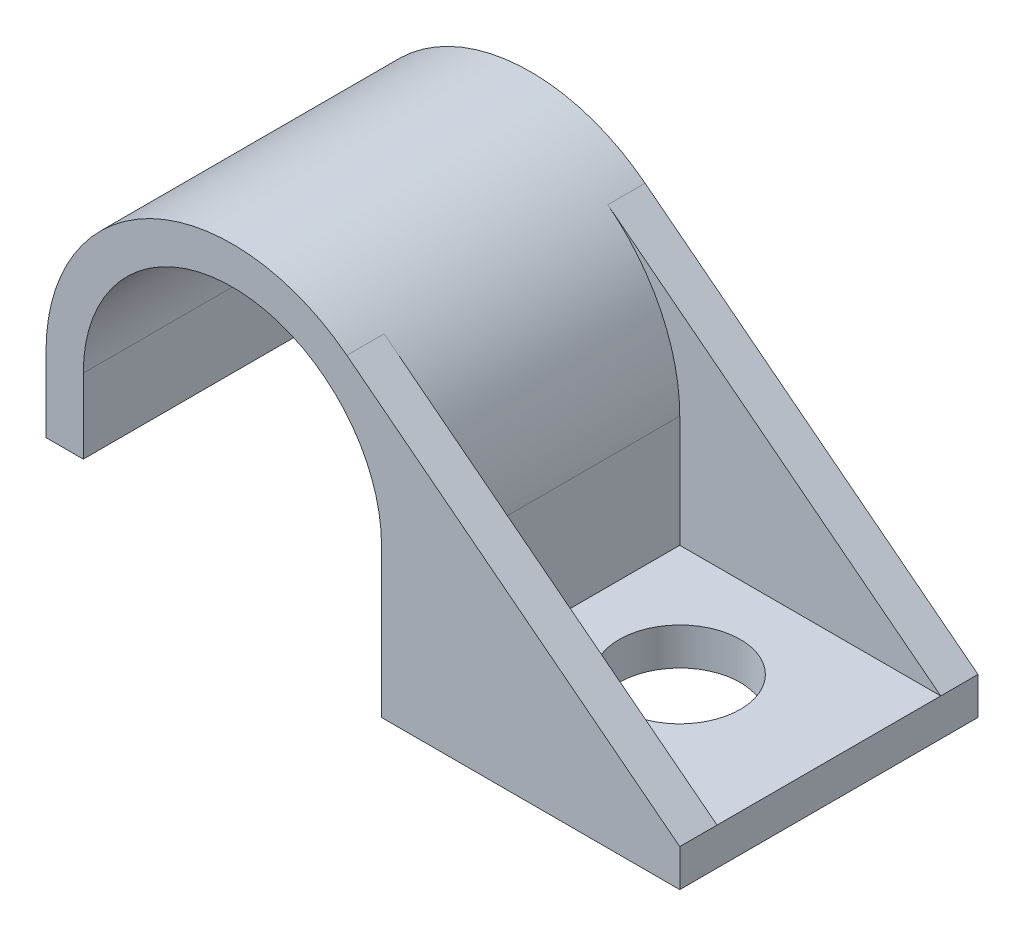
from build123d import *

# Parameters (mm, degrees)
BOSS_EXTRUDE1_DEPTH            = 6.35
CUT_EXTRUDE3_START             = 1.5875
SKETCH4_W                      = 11.112499999999997
SKETCH4_H                      = 9.524999999999999
CUT_EXTRUDE3_DEPTH             = 24.057127330312788
CUT_EXTRUDE4_REACH             = 26.645
CUT_EXTRUDE4_DIRECTION_2_REACH = 26.645
SKETCH3_R                      = 2.5796875
CUT_EXTRUDE2_DEPTH             = 2.54


with BuildPart() as part:
    # Sketch1 → Boss-Extrude1 (new, symmetric)
    with BuildSketch(Plane.XY):
        with BuildLine():
            Line((-7.9375, 3.174999999999999), (-7.9375, 6.35))
            ThreePointArc((-7.9375, 6.35), (-3.487109685994719, 13.480495935616386), (4.873579631582188, 12.615151859662083))
            Line((4.873579631582188, 12.615151859662083), (19.049999999999997, 1.5875000000000004))
            Line((19.049999999999997, 1.5875000000000004), (19.049999999999997, 0))
            Line((19.049999999999997, 0), (6.350000000000001, -1.56e-15))
            Line((6.350000000000001, -1.56e-15), (6.35, 6.3500000000000005))
            ThreePointArc((6.35, 6.3500000000000005), (-1.02e-15, 12.7), (-6.35, 6.349999999999999))
            Line((-6.35, 6.349999999999999), (-6.35, 3.175))
            Line((-6.35, 3.175), (-7.9375, 3.174999999999999))
        make_face()
    extrude(amount=BOSS_EXTRUDE1_DEPTH, both=True)

    # Sketch4 → Cut-Extrude3 (cut, through all)
    with BuildSketch(Plane(origin=(0, 0, 0), x_dir=(1, 0, 0), z_dir=(0, 1, 0)).offset(CUT_EXTRUDE3_START)):
        with Locations((13.493749999999999, 0)):
            Rectangle(SKETCH4_W, SKETCH4_H)
    extrude(amount=CUT_EXTRUDE3_DEPTH, mode=Mode.SUBTRACT)

    # Cut-Extrude4: up to this face of the body (flat: up to its plane)
    cut_extrude4_end = Plane(part.part.faces().sort_by_distance((11.641666667, 4.468922769, 4.7625))[0])
    # Sketch5 → Cut-Extrude4 (cut, up to the picked face)
    with BuildSketch(Plane.XY, mode=Mode.PRIVATE) as cut_extrude4_sk1:
        with BuildLine():
            Line((7.9375, 6.35), (7.9375, 10.231768306511267))
            Line((7.9375, 10.231768306511267), (4.873579631582187, 12.615151859662081))
            ThreePointArc((4.873579631582187, 12.615151859662081), (7.130495935616386, 9.83710968599472), (7.9375, 6.35))
        make_face()
    cut_extrude4_tool1 = split(extrude(cut_extrude4_sk1.sketch, amount=CUT_EXTRUDE4_REACH, mode=Mode.PRIVATE), bisect_by=cut_extrude4_end, keep=Keep.BOTH, mode=Mode.PRIVATE)
    add(cut_extrude4_tool1.solids().sort_by(Axis((7.302263, 9.921111, 0), (0, 0, 1)))[0], mode=Mode.SUBTRACT)

    # Cut-Extrude4 direction 2: up to this face of the body (flat: up to its plane)
    cut_extrude4_direction_2_end = Plane(part.part.faces().sort_by_distance((11.641666667, 4.468922769, -4.7625))[0])
    # Sketch5 → Cut-Extrude4 direction 2 (cut, up to the picked face)
    with BuildSketch(Plane.XY, mode=Mode.PRIVATE) as cut_extrude4_direction_2_sk1:
        with BuildLine():
            Line((7.9375, 6.35), (7.9375, 10.231768306511267))
            Line((7.9375, 10.231768306511267), (4.873579631582187, 12.615151859662081))
            ThreePointArc((4.873579631582187, 12.615151859662081), (7.130495935616386, 9.83710968599472), (7.9375, 6.35))
        make_face()
    cut_extrude4_direction_2_tool1 = split(extrude(cut_extrude4_direction_2_sk1.sketch, amount=-CUT_EXTRUDE4_DIRECTION_2_REACH, mode=Mode.PRIVATE), bisect_by=cut_extrude4_direction_2_end, keep=Keep.BOTH, mode=Mode.PRIVATE)
    add(cut_extrude4_direction_2_tool1.solids().sort_by(Axis((7.302263, 9.921111, 0), (0, 0, -1)))[0], mode=Mode.SUBTRACT)

    # Sketch3 → Cut-Extrude2 (cut)
    with BuildSketch(Plane(origin=(0, 0, 0), x_dir=(1, 0, 0), z_dir=(0, 1, 0))):
        with Locations(Location((12.7, 0, 0), (0, 0, 270))):
            Circle(SKETCH3_R)
    extrude(amount=CUT_EXTRUDE2_DEPTH, mode=Mode.SUBTRACT)


solid = part.part
